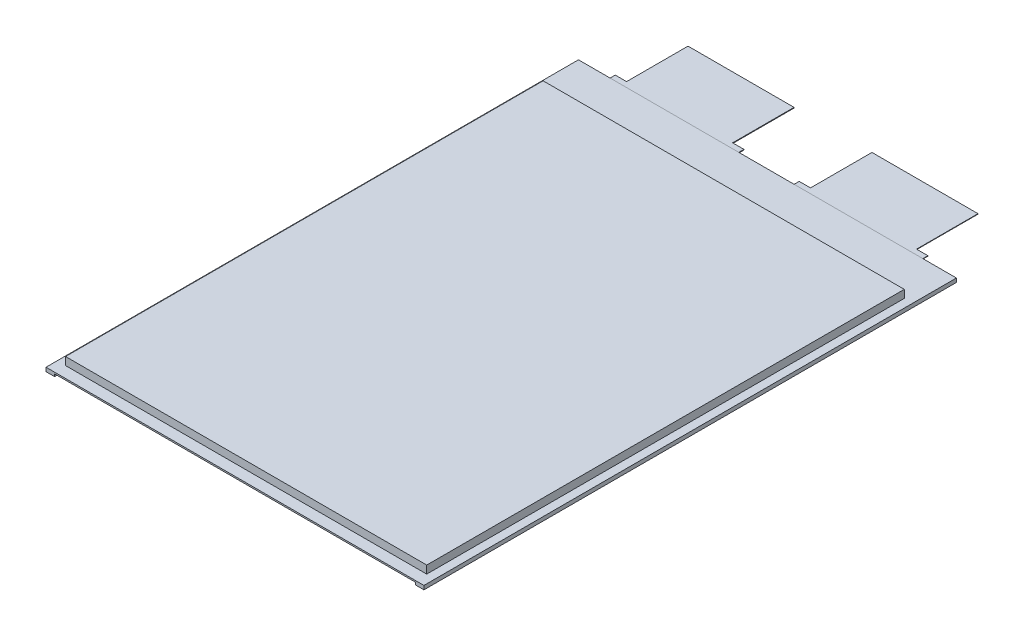
from build123d import *

# Parameters (mm, degrees)
SKETCH1_W             = 153.9875
SKETCH1_H             = 203.596875
CELL_INSULATION_DEPTH = 0.3175
CELL_BODY_DEPTH       = 3.6703
CELL_BODY_DEPTH_BACK  = 3.4163
SKETCH1_3_W           = 153.9875
SKETCH1_3_H           = 203.596875
ANODE_TAB_DEPTH       = 0.1016
CATHODE_TAB_DEPTH     = 0.1397
SKETCH2_W             = 3.683
SKETCH2_H             = 227.0125
EDGE_FOLD_DEPTH       = 1.016


with BuildPart() as part:
    # Sketch1 → Cell Insulation (new, symmetric)
    with BuildSketch(Plane(origin=(0, 0, 0), x_dir=(1, 0, 0), z_dir=(0, 1, 0))):
        Polygon((0, 227.0125), (0, 0), (161.13125, 0), (161.13125, 227.0125), (146.58975, 227.0125), (141.76375, 227.0125), (96.55175, 227.0125), (91.72575, 227.0125), (68.16725, 227.0125), (63.34125, 227.0125), (18.12925, 227.0125), (13.30325, 227.0125), align=None)
        with Locations((80.565625, 106.5609375)):
            Rectangle(SKETCH1_W, SKETCH1_H, mode=Mode.SUBTRACT)
    extrude(amount=CELL_INSULATION_DEPTH, both=True)

    # Sketch1_3 → Cell Body (add, two sides: drawn at the far end of the back side and taken through both)
    with BuildSketch(Plane(origin=(0, 0, 0), x_dir=(1, 0, 0), z_dir=(0, 1, 0)).offset(-CELL_BODY_DEPTH_BACK)):
        with Locations((80.565625, 106.5609375)):
            Rectangle(SKETCH1_3_W, SKETCH1_3_H)
    extrude(amount=CELL_BODY_DEPTH + CELL_BODY_DEPTH_BACK)

    # Sketch1_4 → Anode Tab (add, symmetric)
    with BuildSketch(Plane(origin=(0, 0, 0), x_dir=(1, 0, 0), z_dir=(0, 1, 0))):
        Polygon((146.58975, 227.0125), (146.58975, 229.39375), (141.76375, 229.39375), (141.76375, 255.5875), (96.55175, 255.5875), (96.55175, 229.39375), (91.72575, 229.39375), (91.72575, 227.0125), align=None)
    extrude(amount=ANODE_TAB_DEPTH, both=True)

    # Sketch1_5 → Cathode Tab (add, symmetric)
    with BuildSketch(Plane(origin=(0, 0, 0), x_dir=(1, 0, 0), z_dir=(0, 1, 0))):
        Polygon((13.30325, 229.39375), (13.30325, 227.0125), (68.16725, 227.0125), (68.16725, 229.39375), (63.34125, 229.39375), (63.34125, 255.5875), (18.12925, 255.5875), (18.12925, 229.39375), align=None)
    extrude(amount=CATHODE_TAB_DEPTH, both=True)

    # Sketch2 → Edge Fold (add)
    with BuildSketch(Plane.XZ.offset(0.3175)):
        with Locations((1.8415, -113.50625)):
            Rectangle(SKETCH2_W, SKETCH2_H)
    edge_fold = extrude(amount=EDGE_FOLD_DEPTH)

    # Edge Folds Mirror: Edge Fold across plane
    add(edge_fold.mirror(Plane.ZY.offset(-80.565625)))


solid = part.part
